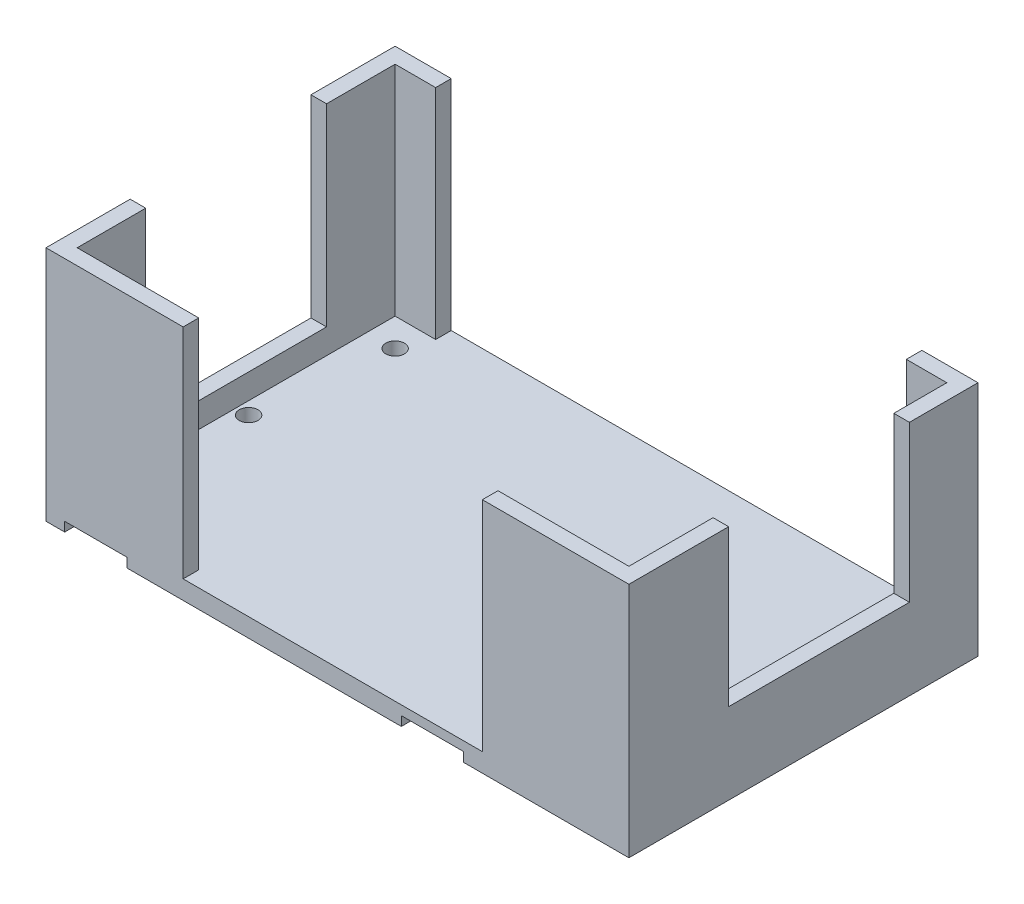
from build123d import *

# Parameters (mm, degrees)
SKETCH2_W           = 93.5
SKETCH2_H           = 56
BOSS_EXTRUDE1_DEPTH = 3
SKETCH3_R           = 1.5
CUT_EXTRUDE5_DEPTH  = 4
SKETCH5_R           = 3.025
CUT_EXTRUDE7_DEPTH  = 2.5
SKETCH6_W           = 2.5
SKETCH6_H           = 2.5
SKETCH6_W_2         = 6.5
SKETCH6_H_2         = 8.5
SKETCH6_W_3         = 21
SKETCH6_H_3         = 11
BOSS_EXTRUDE2_DEPTH = 35
SKETCH8_R           = 1.5
CUT_EXTRUDE8_DEPTH  = 4
SKETCH9_W           = 10
SKETCH9_H           = 2
CUT_EXTRUDE9_DEPTH  = 1.5
SKETCH11_W          = 2.5
SKETCH11_H          = 29
BOSS_EXTRUDE4_DEPTH = 10
SKETCH12_W          = 2.5
SKETCH12_H          = 29
BOSS_EXTRUDE5_DEPTH = 4


with BuildPart() as part:
    # Sketch2 → Boss-Extrude1 (new body)
    with BuildSketch(Plane(origin=(0, 0, 0), x_dir=(1, 0, 0), z_dir=(0, 1, 0))):
        with Locations((-29.736211897, 0.601935214)):
            Rectangle(SKETCH2_W, SKETCH2_H)
    extrude(amount=BOSS_EXTRUDE1_DEPTH)

    # Sketch3 → Cut-Extrude5 (cut, through all)
    with BuildSketch(Plane(origin=(0, 3, 0), x_dir=(1, 0, 0), z_dir=(0, 1, 0))):
        with Locations((-13.486211897, 12.601935214)):
            Circle(SKETCH3_R)
        with Locations((-13.486211897, -11.398064786)):
            Circle(SKETCH3_R)
        with Locations((-71.986211897, 0.601935214)):
            Circle(SKETCH3_R)
    extrude(amount=-CUT_EXTRUDE5_DEPTH, mode=Mode.SUBTRACT)

    # Sketch5 → Cut-Extrude7 (cut)
    with BuildSketch(Plane(origin=(0, 0, 0), x_dir=(-1, 0, 0), z_dir=(0, -1, 0))):
        with Locations((26.486211897, 15.851935214)):
            Circle(SKETCH5_R)
        with Locations((26.486211897, -14.648064786)):
            Circle(SKETCH5_R)
        with Locations((56.986211897, -14.648064786)):
            Circle(SKETCH5_R)
        with Locations((56.986211897, 15.851935214)):
            Circle(SKETCH5_R)
    extrude(amount=-CUT_EXTRUDE7_DEPTH, mode=Mode.SUBTRACT)

    # Sketch6 → Boss-Extrude2 (add)
    with BuildSketch(Plane(origin=(0, 3, 0), x_dir=(1, 0, 0), z_dir=(0, 1, 0))):
        with Locations((15.763788103, 27.351935214)):
            Rectangle(SKETCH6_W, SKETCH6_H)
        with Locations((11.263788103, 27.351935214)):
            Rectangle(SKETCH6_W_2, SKETCH6_H)
        with Locations((15.763788103, 21.851935214)):
            Rectangle(SKETCH6_W, SKETCH6_H_2)
        Polygon((17.013788103, -11.398064786), (14.513788103, -11.398064786), (14.513788103, -24.898064786), (14.513788103, -27.398064786), (17.013788103, -27.398064786), align=None)
        with Locations((4.013788103, -26.148064786)):
            Rectangle(SKETCH6_W_3, SKETCH6_H)
        with Locations((-75.236211897, -19.398064786)):
            Rectangle(SKETCH6_W, SKETCH6_H_3)
        Polygon((-73.986211897, -24.898064786), (-76.486211897, -24.898064786), (-76.486211897, -27.398064786), (-54.486211897, -27.398064786), (-54.486211897, -24.898064786), align=None)
        Polygon((-76.486211897, 28.601935214), (-76.486211897, 26.101935214), (-73.986211897, 26.101935214), (-67.486211897, 26.101935214), (-67.486211897, 28.601935214), align=None)
        with Locations((-75.236211897, 20.601935214)):
            Rectangle(SKETCH6_W, SKETCH6_H_3)
    extrude(amount=BOSS_EXTRUDE2_DEPTH)

    # Sketch8 → Cut-Extrude8 (cut, through all)
    with BuildSketch(Plane(origin=(0, 3, 0), x_dir=(1, 0, 0), z_dir=(0, 1, 0))):
        with Locations((-69.486211897, -20.398064786)):
            Circle(SKETCH8_R)
        with Locations((-69.486211897, 21.601935214)):
            Circle(SKETCH8_R)
        with Locations((9.513788103, -20.398064786)):
            Circle(SKETCH8_R)
        with Locations((9.513788103, 21.601935214)):
            Circle(SKETCH8_R)
    extrude(amount=-CUT_EXTRUDE8_DEPTH, mode=Mode.SUBTRACT)

    # Sketch9 → Cut-Extrude9 (cut)
    with BuildSketch(Plane(origin=(0, 0, 0), x_dir=(-1, 0, 0), z_dir=(0, -1, 0))):
        with Locations((68.486211897, 27.601935214)):
            Rectangle(SKETCH9_W, SKETCH9_H)
        with Locations((68.486211897, -26.398064786)):
            Rectangle(SKETCH9_W, SKETCH9_H)
        with Locations((14.486211897, 27.601935214)):
            Rectangle(SKETCH9_W, SKETCH9_H)
        with Locations((14.486211897, -26.398064786)):
            Rectangle(SKETCH9_W, SKETCH9_H)
    extrude(amount=-CUT_EXTRUDE9_DEPTH, mode=Mode.SUBTRACT)

    # Sketch11 → Boss-Extrude4 (add)
    with BuildSketch(Plane(origin=(0, 3, 0), x_dir=(1, 0, 0), z_dir=(0, 1, 0))):
        with Locations((15.763788103, 3.101935214)):
            Rectangle(SKETCH11_W, SKETCH11_H)
    extrude(amount=BOSS_EXTRUDE4_DEPTH)

    # Sketch12 → Boss-Extrude5 (add)
    with BuildSketch(Plane(origin=(0, 3, 0), x_dir=(1, 0, 0), z_dir=(0, 1, 0))):
        with Locations((-75.236211897, 0.601935214)):
            Rectangle(SKETCH12_W, SKETCH12_H)
    extrude(amount=BOSS_EXTRUDE5_DEPTH)


solid = part.part
